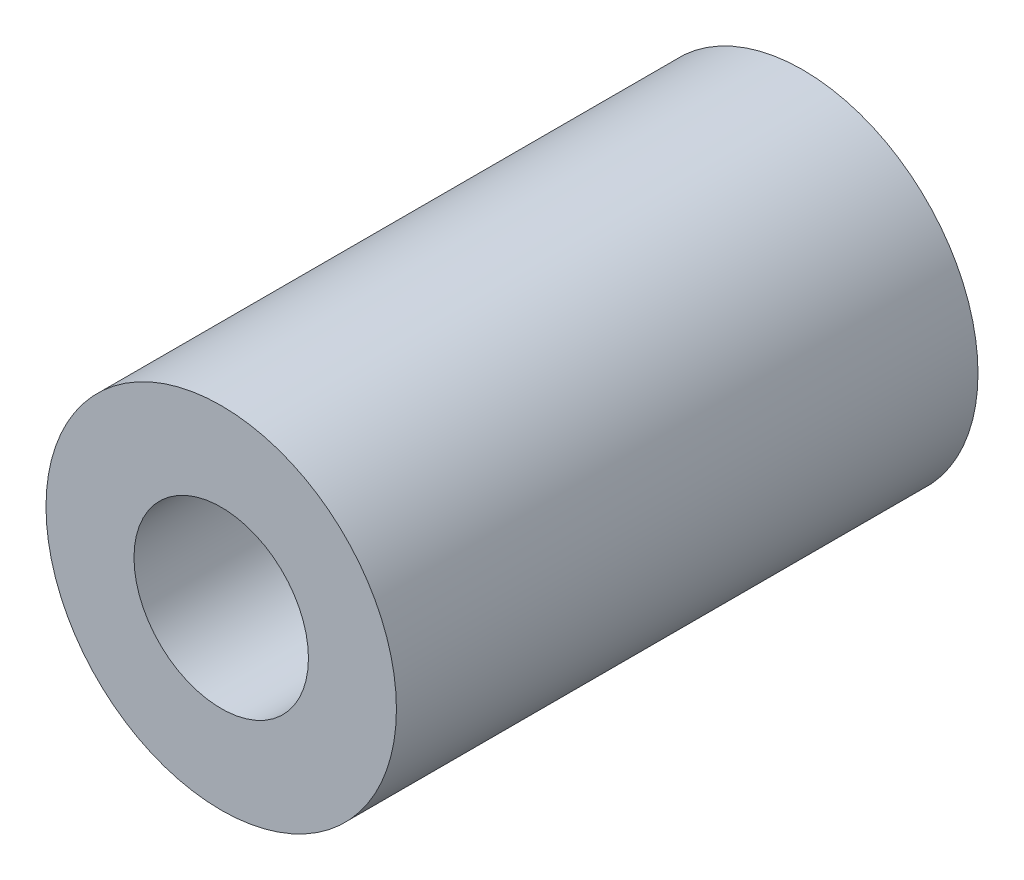
from build123d import *

# Parameters (mm, degrees)
SKETCH3_R                = 6.0255
SKETCH3_R_2              = 3
BOSS_EXTRUDE1_DEPTH      = 10
BOSS_EXTRUDE1_DEPTH_BACK = 10


with BuildPart() as part:
    # Sketch3 → Boss-Extrude1 (new body, two sides)
    with BuildSketch(Plane.XY) as boss_extrude1_sk:
        Circle(SKETCH3_R)
        Circle(SKETCH3_R_2, mode=Mode.SUBTRACT)
    extrude(amount=BOSS_EXTRUDE1_DEPTH)
    extrude(boss_extrude1_sk.sketch, amount=-BOSS_EXTRUDE1_DEPTH_BACK)


solid = part.part
